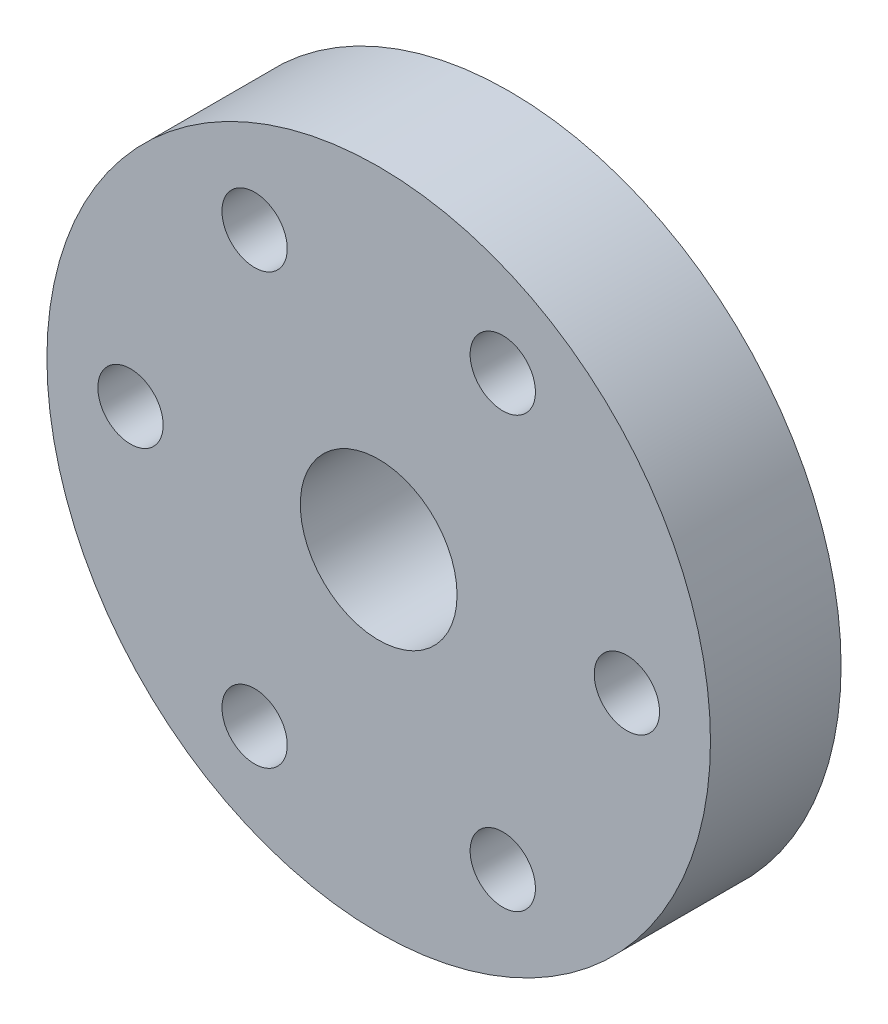
from build123d import *

# Parameters (mm, degrees)
TAP_DRILL_FOR_M3X0_5_TAP1_D     = 2.5
TAP_DRILL_FOR_M3X0_5_TAP1_DEPTH = 10
TAP_DRILL_FOR_M3X0_5_TAP1_TIP   = 0.751075774


with BuildPart() as part:
    # Sketch1 → Revolve1 (revolve)
    with BuildSketch(Plane(origin=(0, 0, 0), x_dir=(0, 0, -1), z_dir=(1, 0, 0))):
        Polygon((0, 3), (0, 12.7), (5, 12.7), (5, 6), (9.2, 6), (9.2, 3), align=None)
    revolve(axis=Axis((0, 0, 50.268991478), (0, 0, -1)))

    # Tap Drill for M3x0.5 Tap1
    with Locations(Plane.XY):
        with Locations((-4.75, 8.227241336), (4.75, 8.227241336), (9.5, 0), (4.75, -8.227241336), (-4.75, -8.227241336), (-9.5, 0)):
            Hole(TAP_DRILL_FOR_M3X0_5_TAP1_D / 2, depth=TAP_DRILL_FOR_M3X0_5_TAP1_DEPTH)
            with Locations((0, 0, -(TAP_DRILL_FOR_M3X0_5_TAP1_DEPTH + TAP_DRILL_FOR_M3X0_5_TAP1_TIP / 2))):  # 118° drill point
                Cone(0, TAP_DRILL_FOR_M3X0_5_TAP1_D / 2, TAP_DRILL_FOR_M3X0_5_TAP1_TIP, mode=Mode.SUBTRACT)


solid = part.part
